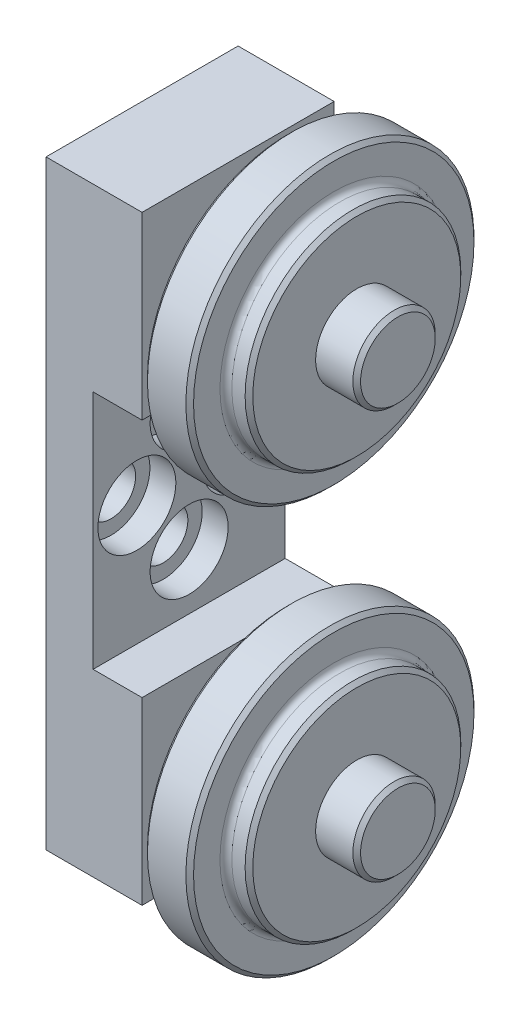
from build123d import *

# Parameters (mm, degrees)
BOSS_EXTRUDE1_DEPTH = 12.7
SKETCH3_R           = 3.175
CUT_EXTRUDE1_DEPTH  = 61.224681503
SKETCH4_R           = 3.2639
CUT_EXTRUDE2_DEPTH  = 57.961872883
SKETCH5_R           = 5.1562
CUT_EXTRUDE3_DEPTH  = 3.429


with BuildPart() as part:
    # Sketch2 → Revolve1 (revolve)
    with BuildSketch(Plane.XY, mode=Mode.PRIVATE) as revolve1_sk:
        with BuildLine():
            Line((3.048, 42.037), (3.048, 45.5295))
            Line((3.048, 45.5295), (2.54, 46.0375))
            Line((2.54, 46.0375), (-2.54, 46.0375))
            Line((-2.54, 46.0375), (-3.048, 45.5295))
            Line((-3.048, 45.5295), (-3.048, 42.037))
            ThreePointArc((-3.048, 42.037), (-3.27862412, 41.48022412), (-3.8354, 41.2496))
            Line((-3.8354, 41.2496), (-5.588, 41.2496))
            Line((-5.588, 41.2496), (-6.096, 40.7416))
            Line((-6.096, 40.7416), (-6.096, 30.1625))
            Line((-6.096, 30.1625), (-6.607025306, 30.1625))
            Line((-6.607025306, 30.1625), (-6.607025306, 34.8869))
            Line((-6.607025306, 34.8869), (-9.6012, 34.8869))
            Line((-9.6012, 34.8869), (-9.6012, 30.1625))
            Line((-9.6012, 30.1625), (-17.1704, 30.1625))
            Line((-17.1704, 30.1625), (-17.6784, 29.6545))
            Line((-17.6784, 29.6545), (-17.6784, 26.9875))
            Line((-17.6784, 26.9875), (11.5316, 26.9875))
            Line((11.5316, 26.9875), (11.5316, 31.9278))
            Line((11.5316, 31.9278), (11.0236, 32.4358))
            Line((11.0236, 32.4358), (6.096, 32.4358))
            Line((6.096, 32.4358), (6.096, 40.7416))
            Line((6.096, 40.7416), (5.588, 41.2496))
            Line((5.588, 41.2496), (3.8354, 41.2496))
            ThreePointArc((3.8354, 41.2496), (3.27862412, 41.48022412), (3.048, 42.037))
        make_face()
    revolve(revolve1_sk.sketch.rotate(Axis((-17.6784, 26.9875, 0), (1, 0, 0)), 90), axis=Axis((-17.6784, 26.9875, 0), (1, 0, 0)))


with BuildPart() as body_2:
    # Sketch1 → Boss-Extrude1 (new, symmetric)
    with BuildSketch(Plane.XY):
        Polygon((-22.3012, 39.6875), (-22.3012, -39.6875), (-9.6012, -39.6875), (-9.6012, -15.8877), (-16.0782, -15.8877), (-16.0782, 15.8877), (-9.6012, 15.8877), (-9.6012, 39.6875), align=None)
    extrude(amount=BOSS_EXTRUDE1_DEPTH, both=True)

    # Sketch3 → Cut-Extrude1 (cut, through all)
    with BuildSketch(Plane.ZY.offset(22.3012)):
        with Locations((0, 26.9875)):
            Circle(SKETCH3_R)
        with Locations((0, -26.9875)):
            Circle(SKETCH3_R)
    extrude(amount=-CUT_EXTRUDE1_DEPTH, mode=Mode.SUBTRACT)

    # Sketch4 → Cut-Extrude2 (cut, through all)
    with BuildSketch(Plane(origin=(-16.0782, 0, 0), x_dir=(0, 0, -1), z_dir=(1, 0, 0))):
        with Locations((0, 8.4963)):
            Circle(SKETCH4_R)
        with Locations((0, -8.4963)):
            Circle(SKETCH4_R)
        with Locations((-6.9088, 0)):
            Circle(SKETCH4_R)
        with Locations((6.9088, 0)):
            Circle(SKETCH4_R)
    extrude(amount=-CUT_EXTRUDE2_DEPTH, mode=Mode.SUBTRACT)

    # Sketch5 → Cut-Extrude3 (cut)
    with BuildSketch(Plane(origin=(-16.0782, 0, 0), x_dir=(0, 0, -1), z_dir=(1, 0, 0))):
        with Locations((0, 8.4963)):
            Circle(SKETCH5_R)
        with Locations((6.9088, 0)):
            Circle(SKETCH5_R)
        with Locations((-6.9088, 0)):
            Circle(SKETCH5_R)
        with Locations((0, -8.4963)):
            Circle(SKETCH5_R)
    extrude(amount=-CUT_EXTRUDE3_DEPTH, mode=Mode.SUBTRACT)


with BuildPart() as body_3:
    # Mirror1: mirrored copy
    add(part.part.mirror(Plane.ZX))


solid = Compound([part.part, body_2.part, body_3.part])
